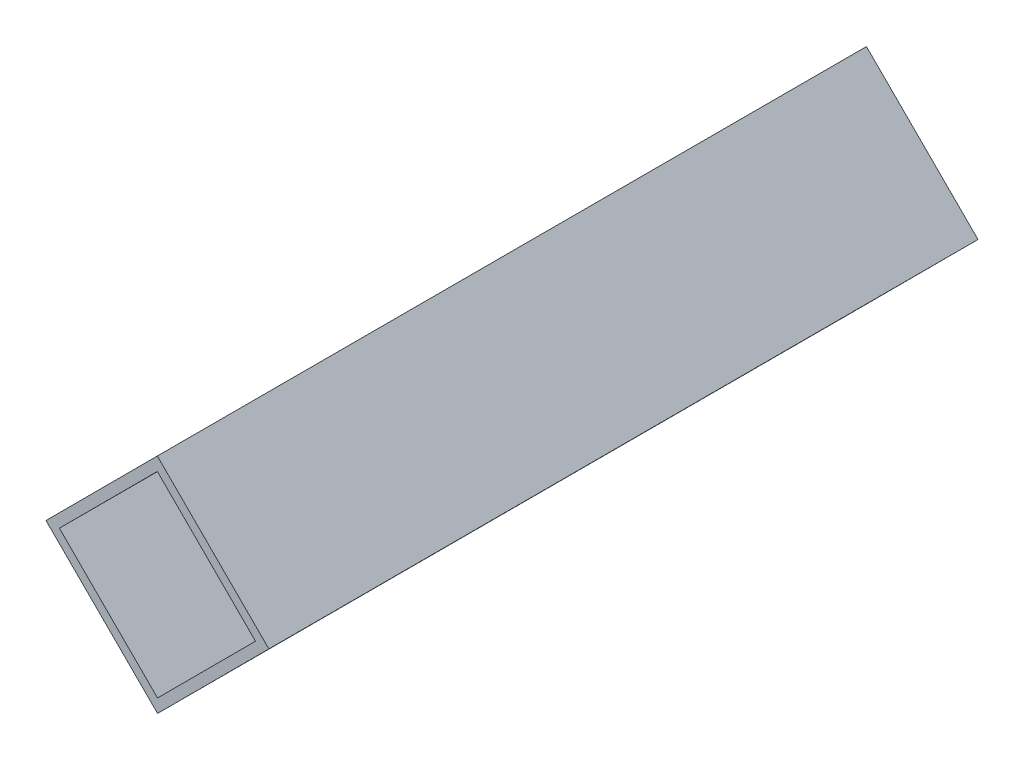
from build123d import *

# Parameters (mm, degrees)
EXTRUDE_1_DEPTH = 112.5


with BuildPart() as part:
    # 草圖1 → 填料-伸長1 (new body)
    with BuildSketch(Plane.XY):
        Polygon((0, 0), (17.69379362, -17.661530719), (0.032262901, -35.355324339), (-17.661530719, -17.69379362), align=None)
        Polygon((0.001935774, -2.12131946), (-15.540211259, -17.691857846), (0.030327127, -33.234004879), (15.57247416, -17.663466493), align=None, mode=Mode.SUBTRACT)
    extrude(amount=EXTRUDE_1_DEPTH)


solid = part.part
